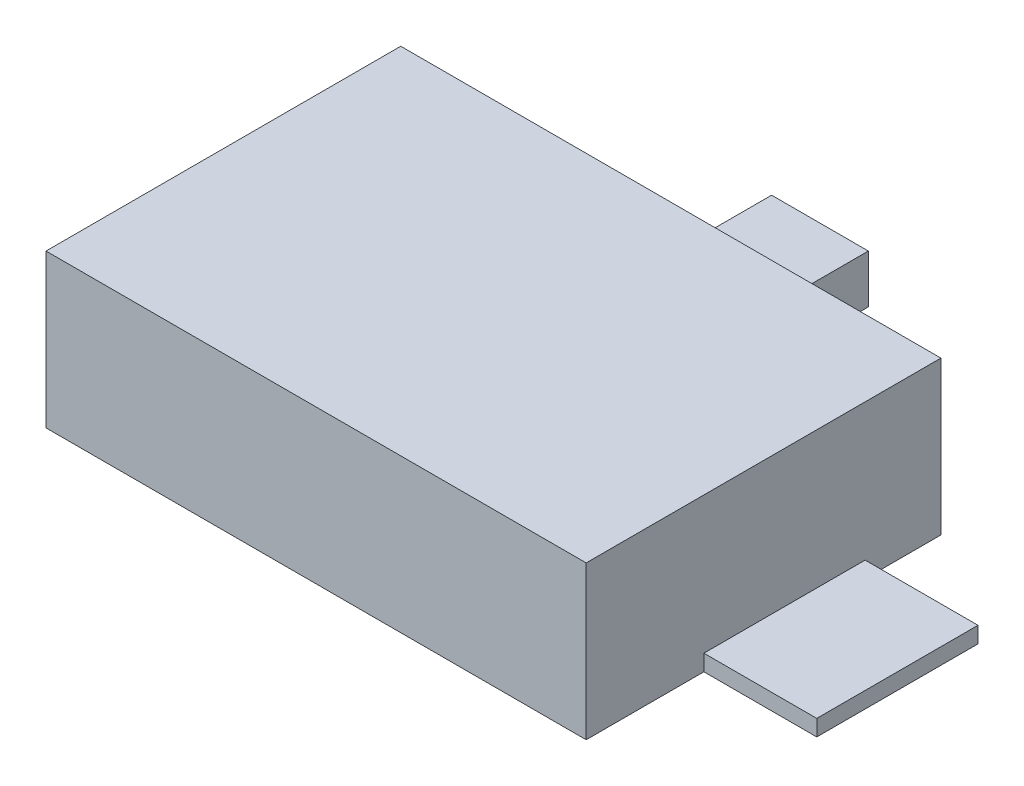
from build123d import *

# Parameters (mm, degrees)
SKETCH1_W           = 85.09
SKETCH1_H           = 55.88
BOSS_EXTRUDE1_DEPTH = 24.13
SKETCH2_W           = 17.78
SKETCH2_H           = 25.4
BOSS_EXTRUDE2_DEPTH = 2.54
SKETCH3_W           = 15.24
SKETCH3_H           = 7.62
BOSS_EXTRUDE3_DEPTH = 25.4


with BuildPart() as part:
    # Sketch1 → Boss-Extrude1 (new body)
    with BuildSketch(Plane(origin=(0, 0, 0), x_dir=(1, 0, 0), z_dir=(0, 1, 0))):
        Rectangle(SKETCH1_W, SKETCH1_H)
    extrude(amount=BOSS_EXTRUDE1_DEPTH)

    # Sketch2 → Boss-Extrude2 (add)
    with BuildSketch(Plane.XZ):
        with Locations((51.435, -3.302)):
            Rectangle(SKETCH2_W, SKETCH2_H)
    extrude(amount=-BOSS_EXTRUDE2_DEPTH)

    # Sketch3 → Boss-Extrude3 (add)
    with BuildSketch(Plane(origin=(0, 0, -27.94), x_dir=(-1, 0, 0), z_dir=(0, 0, -1))):
        with Locations((1.905, 3.81)):
            Rectangle(SKETCH3_W, SKETCH3_H)
    extrude(amount=BOSS_EXTRUDE3_DEPTH)


solid = part.part
